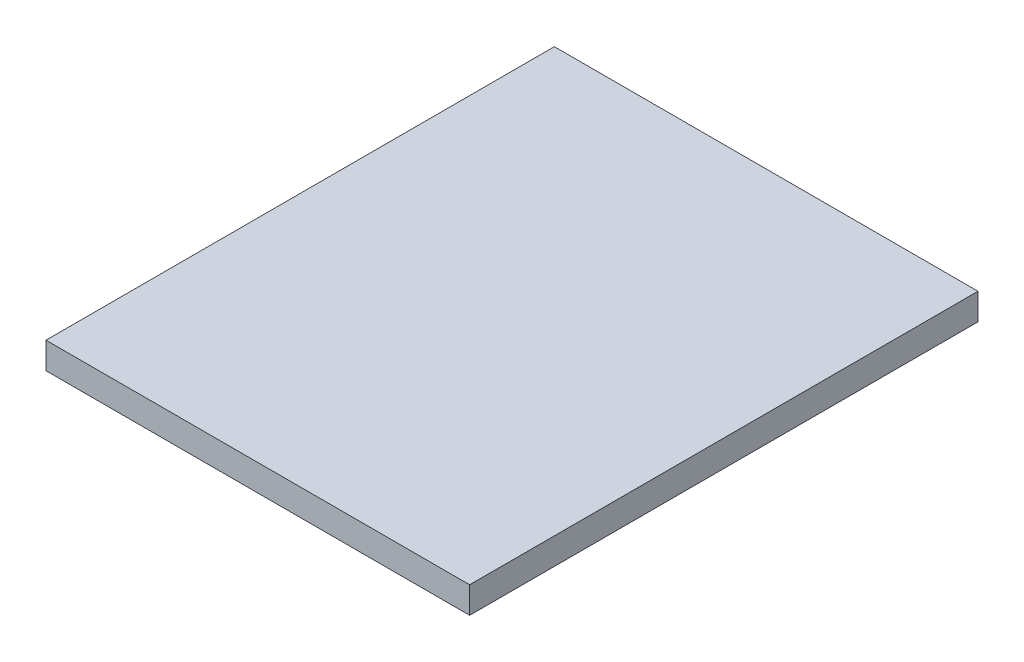
from build123d import *

# Parameters (mm, degrees)
SKETCH1_W           = 50.8
SKETCH1_H           = 60.96
BOSS_EXTRUDE1_DEPTH = 3.175


with BuildPart() as part:
    # Sketch1 → Boss-Extrude1 (new body)
    with BuildSketch(Plane(origin=(0, 0, 0), x_dir=(1, 0, 0), z_dir=(0, 1, 0))):
        with Locations((-21.824805354, 4.109944456)):
            Rectangle(SKETCH1_W, SKETCH1_H)
    extrude(amount=BOSS_EXTRUDE1_DEPTH)


solid = part.part
